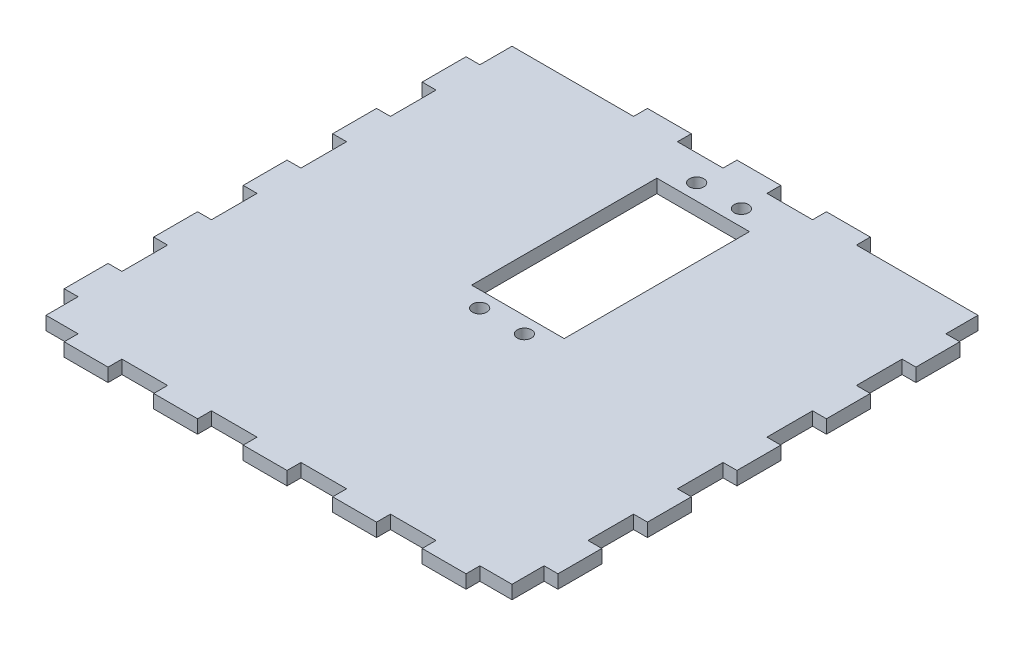
from build123d import *

# Parameters (mm, degrees)
SKETCH1_W           = 110.344434204
SKETCH1_H           = 110.344434204
SKETCH1_R           = 1.6
SKETCH1_W_2         = 20.7
SKETCH1_H_2         = 41.4
BOSS_EXTRUDE1_DEPTH = 3
SKETCH3_W           = 3.2
SKETCH3_H           = 10.2
SKETCH3_W_2         = 10.2
SKETCH3_H_2         = 3.2
CUT_EXTRUDE1_DEPTH  = 4


with BuildPart() as part:
    # Sketch1 → Boss-Extrude1 (new body)
    with BuildSketch(Plane(origin=(0, 0, 0), x_dir=(1, 0, 0), z_dir=(0, 1, 0))):
        with Locations((0, -11.670773756)):
            Rectangle(SKETCH1_W, SKETCH1_H)
        with Locations((-5, 34.6)):
            Circle(SKETCH1_R, mode=Mode.SUBTRACT)
        with Locations((5, 34.6)):
            Circle(SKETCH1_R, mode=Mode.SUBTRACT)
        with Locations((5, -13.9)):
            Circle(SKETCH1_R, mode=Mode.SUBTRACT)
        with Locations((-5, -13.9)):
            Circle(SKETCH1_R, mode=Mode.SUBTRACT)
        with Locations((0, 10.35)):
            Rectangle(SKETCH1_W_2, SKETCH1_H_2, mode=Mode.SUBTRACT)
    extrude(amount=BOSS_EXTRUDE1_DEPTH)

    # Sketch3 → Cut-Extrude1 (cut, through all)
    with BuildSketch(Plane(origin=(0, 0, 0), x_dir=(1, 0, 0), z_dir=(0, 1, 0))):
        Polygon((-55.272217102, 43.601443346), (-55.272217102, 33.229226244), (-52.072217102, 33.229226244), (-52.072217102, 40.401443346), (-24.9, 40.401443346), (-24.9, 43.601443346), align=None)
        with Locations((-53.672217102, -1.670773756)):
            Rectangle(SKETCH3_W, SKETCH3_H)
        with Locations((-53.672217102, 18.329226244)):
            Rectangle(SKETCH3_W, SKETCH3_H)
        with Locations((-10, 42.001443346)):
            Rectangle(SKETCH3_W_2, SKETCH3_H_2)
        with Locations((-10, -65.342990858)):
            Rectangle(SKETCH3_W_2, SKETCH3_H_2)
        with Locations((-30, -65.342990858)):
            Rectangle(SKETCH3_W_2, SKETCH3_H_2)
        Polygon((-55.272217102, -56.570773756), (-52.072217102, -56.570773756), (-52.072217102, -63.742990858), (-44.9, -63.742990858), (-44.9, -66.942990858), (-55.272217102, -66.942990858), align=None)
        with Locations((-53.672217102, -21.670773756)):
            Rectangle(SKETCH3_W, SKETCH3_H)
        with Locations((-53.672217102, -41.670773756)):
            Rectangle(SKETCH3_W, SKETCH3_H)
        with Locations((30, -65.342990858)):
            Rectangle(SKETCH3_W_2, SKETCH3_H_2)
        with Locations((10, -65.342990858)):
            Rectangle(SKETCH3_W_2, SKETCH3_H_2)
        with Locations((53.672217102, -41.670773756)):
            Rectangle(SKETCH3_W, SKETCH3_H)
        with Locations((53.672217102, -21.670773756)):
            Rectangle(SKETCH3_W, SKETCH3_H)
        Polygon((52.072217102, -56.570773756), (52.072217102, -63.742990858), (44.9, -63.742990858), (44.9, -66.942990858), (55.272217102, -66.942990858), (55.272217102, -56.570773756), align=None)
        with Locations((53.672217102, -1.670773756)):
            Rectangle(SKETCH3_W, SKETCH3_H)
        with Locations((53.672217102, 18.329226244)):
            Rectangle(SKETCH3_W, SKETCH3_H)
        Polygon((24.9, 43.601443346), (24.9, 40.401443346), (52.072217102, 40.401443346), (52.072217102, 33.229226244), (55.272217102, 33.229226244), (55.272217102, 43.601443346), align=None)
        with Locations((10, 42.001443346)):
            Rectangle(SKETCH3_W_2, SKETCH3_H_2)
    extrude(amount=CUT_EXTRUDE1_DEPTH, mode=Mode.SUBTRACT)


solid = part.part
